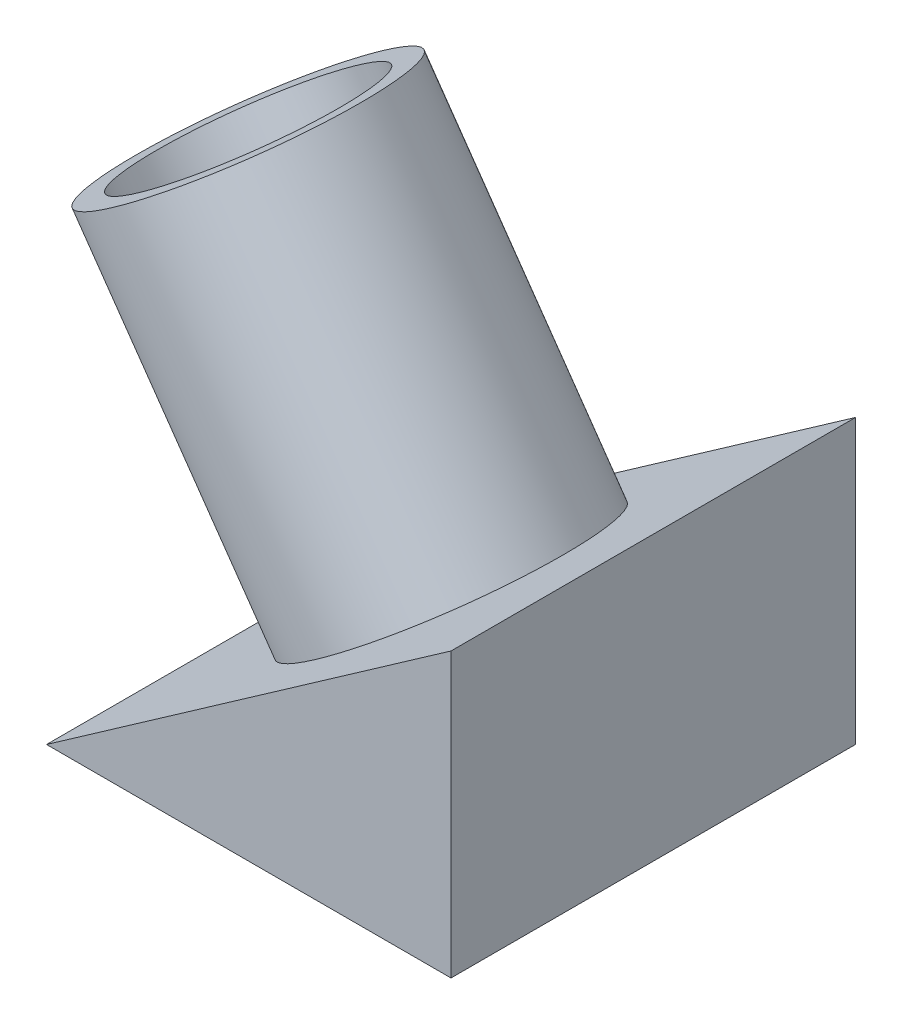
from build123d import *

# Parameters (mm, degrees)
BOSS_EXTRUDE1_DEPTH = 40
SKETCH3_R           = 13.5
BOSS_EXTRUDE2_DEPTH = 35
SKETCH4_R           = 11
CUT_EXTRUDE1_DEPTH  = 35


with BuildPart() as part:
    # Sketch2 → Boss-Extrude1 (new body)
    with BuildSketch(Plane.XY):
        Polygon((0, 0), (40, 28.008301528), (40, 0), align=None)
    extrude(amount=BOSS_EXTRUDE1_DEPTH)

    # Sketch3 → Boss-Extrude2 (add)
    with BuildSketch(Plane(origin=(0, 0, 0), x_dir=(0.819152044, 0.573576436, 0), z_dir=(-0.573576436, 0.819152044, 0))):
        with Locations((24.415, -19.983681398)):
            Circle(SKETCH3_R)
    extrude(amount=BOSS_EXTRUDE2_DEPTH)

    # Sketch4 → Cut-Extrude1 (cut)
    with BuildSketch(Plane(origin=(-20.075175272, 28.67032155, 0), x_dir=(0.819152044, 0.573576436, 0), z_dir=(-0.573576436, 0.819152044, 0))):
        with Locations((24.415, -19.983681398)):
            Circle(SKETCH4_R)
    extrude(amount=-CUT_EXTRUDE1_DEPTH, mode=Mode.SUBTRACT)


solid = part.part
